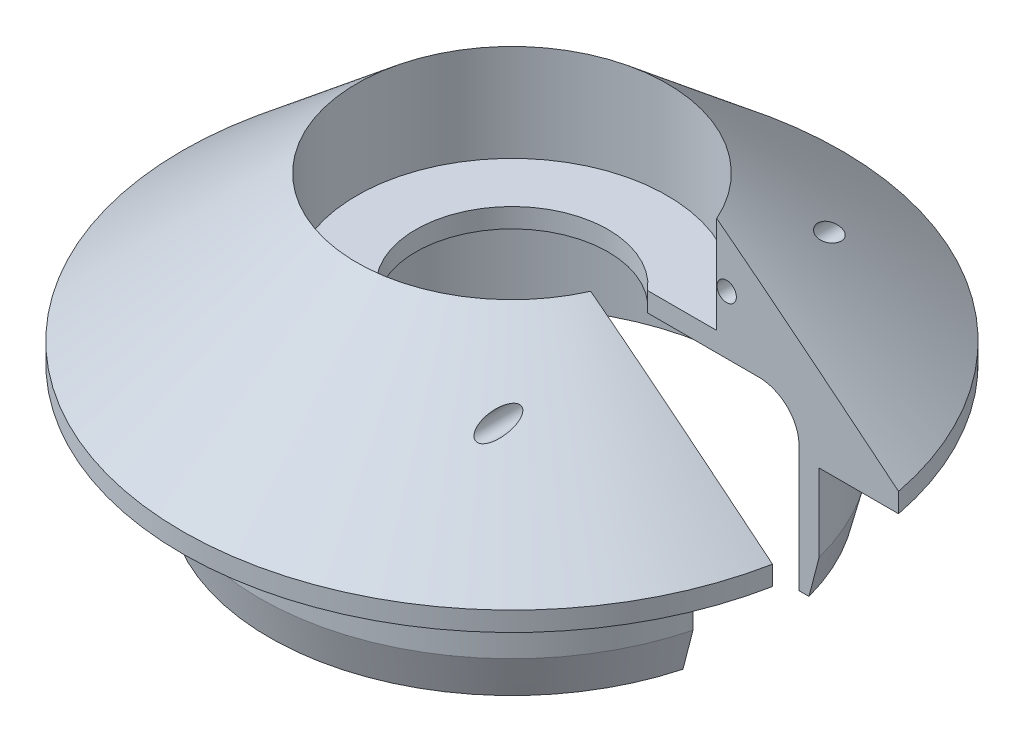
from build123d import *

# Parameters (mm, degrees)
SKETCH3_W           = 26.9875
SKETCH3_H           = 10.31875
EXTRUDE1_DEPTH      = 10.525
EXTRUDE1_DEPTH_BACK = 14.49375
SKETCH4_R           = 0.79375
EXTRUDE2_DEPTH      = 27.9875
EXTRUDE2_DEPTH_BACK = 27.9875


with BuildPart() as part:
    # Sketch2 → Revolve1 (revolve)
    with BuildSketch(Plane(origin=(0, 0, 0), x_dir=(0, 0, -1), z_dir=(1, 0, 0))):
        with BuildLine():
            Line((12.7, 9.525), (12.7, 1.5875))
            Line((12.7, 1.5875), (7.874, 1.5875))
            Line((7.874, 1.5875), (7.874, 0))
            Line((7.874, 0), (15.875, 0))
            ThreePointArc((15.875, 0), (18.12006403, -0.92993597), (19.05, -3.175))
            Line((19.05, -3.175), (19.05, -13.49375))
            Line((19.05, -13.49375), (19.84375, -13.49375))
            Line((19.84375, -13.49375), (20.6375, -10.31875))
            Line((20.6375, -10.31875), (20.6375, -3.96875))
            Line((20.6375, -3.96875), (26.9875, -3.96875))
            Line((26.9875, -3.96875), (26.9875, -2.38125))
            Line((26.9875, -2.38125), (12.7, 9.525))
        make_face()
    revolve(axis=Axis((0, 42.481442496, 0), (0, -1, 0)))

    # Sketch3 → Extrude1 (cut, two sides)
    with BuildSketch(Plane(origin=(0, 0, 0), x_dir=(1, 0, 0), z_dir=(0, 1, 0))) as extrude1_sk:
        with Locations((13.49375, 0)):
            Rectangle(SKETCH3_W, SKETCH3_H)
    extrude(amount=EXTRUDE1_DEPTH, mode=Mode.SUBTRACT)
    extrude(extrude1_sk.sketch, amount=-EXTRUDE1_DEPTH_BACK, mode=Mode.SUBTRACT)

    # Sketch4 → Extrude2 (cut, two sides)
    with BuildSketch(Plane.XY) as extrude2_sk:
        with Locations((12.417577017, 4.7625)):
            Circle(SKETCH4_R)
    extrude(amount=EXTRUDE2_DEPTH, mode=Mode.SUBTRACT)
    extrude(extrude2_sk.sketch, amount=-EXTRUDE2_DEPTH_BACK, mode=Mode.SUBTRACT)


solid = part.part
